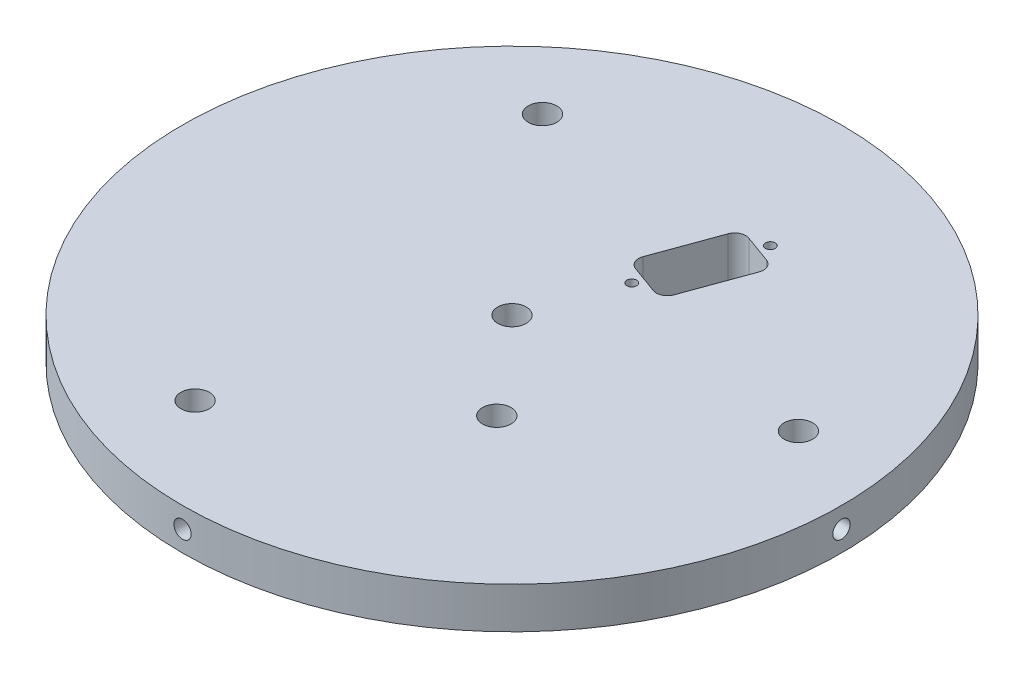
from build123d import *

# Parameters (mm, degrees)
SKETCH1_R                 = 78.359
BOSS_EXTRUDE1_DEPTH       = 25.4
SKETCH6_R                 = 76.1746
BOSS_EXTRUDE5_DEPTH       = 9.525
SKETCH7_R                 = 76.1746
BOSS_EXTRUDE6_DEPTH       = 9.525
SKETCH8_R                 = 73.025
CUT_EXTRUDE5_DEPTH        = 34.925
SKETCH3_R                 = 2
CUT_EXTRUDE2_DEPTH        = 9.525
CUT_EXTRUDE3_START        = 25.4
SKETCH1_7_R               = 78.359
SKETCH1_7_R_2             = 76.1746
CUT_EXTRUDE3_DEPTH        = 9.525
CIRPATTERN2_COUNT         = 3
SKETCH4_R                 = 73.025
BOSS_EXTRUDE4_DEPTH       = 9.525
CIRPATTERN3_COUNT         = 4
SKETCH9_R                 = 3.3
CUT_EXTRUDE6_DEPTH        = 45.4500001
SKETCH10_R                = 82.322787435
CUT_EXTRUDE7_DEPTH        = 35.9250001
TAP_DRILL_FOR_4_40_TAP1_D = 2.2606
CUT_EXTRUDE9_DEPTH        = 10.5250001


with BuildPart() as part:
    # Sketch1 → Boss-Extrude1 (new body)
    with BuildSketch(Plane(origin=(0, 0, 0), x_dir=(1, 0, 0), z_dir=(0, 1, 0))):
        Circle(SKETCH1_R)
    extrude(amount=BOSS_EXTRUDE1_DEPTH)

    # Sketch6 → Boss-Extrude5 (add)
    with BuildSketch(Plane(origin=(0, 25.4, 0), x_dir=(1, 0, 0), z_dir=(0, 1, 0))):
        Circle(SKETCH6_R)
    extrude(amount=BOSS_EXTRUDE5_DEPTH)

    # Sketch7 → Boss-Extrude6 (add)
    with BuildSketch(Plane.XZ):
        Circle(SKETCH7_R)
    extrude(amount=BOSS_EXTRUDE6_DEPTH)

    # Sketch8 → Cut-Extrude5 (cut)
    with BuildSketch(Plane.XZ.offset(9.525)):
        Circle(SKETCH8_R)
    extrude(amount=-CUT_EXTRUDE5_DEPTH, mode=Mode.SUBTRACT)

    # Sketch3 → Cut-Extrude2 (cut)
    with BuildSketch(Plane(origin=(0, 0, -76.1746), x_dir=(-1, 0, 0), z_dir=(0, 0, -1))):
        with Locations((0, 30.1625)):
            Circle(SKETCH3_R)
        with Locations((0, -4.7625)):
            Circle(SKETCH3_R)
    cut_extrude2 = extrude(amount=-CUT_EXTRUDE2_DEPTH, mode=Mode.SUBTRACT)

    # Sketch1_7 → Cut-Extrude3 (cut)
    with BuildSketch(Plane(origin=(0, 0, 0), x_dir=(1, 0, 0), z_dir=(0, 1, 0)).offset(CUT_EXTRUDE3_START)):
        Circle(SKETCH1_7_R)
        Circle(SKETCH1_7_R_2, mode=Mode.SUBTRACT)
    cut_extrude3 = extrude(amount=-CUT_EXTRUDE3_DEPTH, mode=Mode.SUBTRACT)

    # CirPattern2: Cut-Extrude3 ×3 about axis
    cirpattern2_axis = Axis((0, 0, 0), (0, 1, 0))
    for i in range(1, CIRPATTERN2_COUNT):
        add(cut_extrude3.rotate(cirpattern2_axis, i * 360 / CIRPATTERN2_COUNT), mode=Mode.SUBTRACT)

    # Sketch4 → Boss-Extrude4 (add)
    with BuildSketch(Plane(origin=(0, 34.925, 0), x_dir=(1, 0, 0), z_dir=(0, 1, 0))):
        Circle(SKETCH4_R)
    extrude(amount=-BOSS_EXTRUDE4_DEPTH)

    # CirPattern3: Cut-Extrude2 ×4 about axis
    cirpattern3_axis = Axis((0, 0, 0), (0, 1, 0))
    for i in range(1, CIRPATTERN3_COUNT):
        add(cut_extrude2.rotate(cirpattern3_axis, i * 360 / CIRPATTERN3_COUNT), mode=Mode.SUBTRACT)

    # Sketch9 → Cut-Extrude6 (cut, through all)
    with BuildSketch(Plane(origin=(0, 34.925, 0), x_dir=(1, 0, 0), z_dir=(0, 1, 0))):
        Circle(SKETCH9_R)
        with Locations((-19.546451191, -53.703433278)):
            Circle(SKETCH9_R)
        with Locations((-36.735311894, 43.779439924)):
            Circle(SKETCH9_R)
        with Locations((56.281763085, 9.923993354)):
            Circle(SKETCH9_R)
        with Locations((18.367655947, -21.889719962)):
            Circle(SKETCH9_R)
    extrude(amount=-CUT_EXTRUDE6_DEPTH, mode=Mode.SUBTRACT)

    # Sketch10 → Cut-Extrude7 (cut, through all)
    with BuildSketch(Plane(origin=(0, 25.4, 0), x_dir=(1, 0, 0), z_dir=(0, 1, 0))):
        Circle(SKETCH10_R)
    extrude(amount=-CUT_EXTRUDE7_DEPTH, mode=Mode.SUBTRACT)

    # Tap Drill for _4-40 Tap1 (through all)
    with Locations(Plane(origin=(0, 34.925, 0), x_dir=(1, 0, 0), z_dir=(0, 1, 0))):
        with Locations((7.384214894, 20.287963683), (15.934718491, 43.780279238)):
            Hole(TAP_DRILL_FOR_4_40_TAP1_D / 2)

    # Sketch14 → Cut-Extrude9 (cut, through all)
    with BuildSketch(Plane(origin=(0, 34.925, 0), x_dir=(1, 0, 0), z_dir=(0, 1, 0))):
        with BuildLine():
            Line((14.64382936, 22.781402035), (19.893154532, 37.203804415))
            ThreePointArc((19.893154532, 37.203804415), (19.808357055, 39.145985964), (18.37506644, 40.459354836))
            Line((18.37506644, 40.459354836), (11.930654446, 42.804928978))
            ThreePointArc((11.930654446, 42.804928978), (9.988472897, 42.720131501), (8.675104025, 41.286840886))
            Line((8.675104025, 41.286840886), (3.425778853, 26.864438506))
            ThreePointArc((3.425778853, 26.864438506), (3.51057633, 24.922256957), (4.943866945, 23.608888085))
            Line((4.943866945, 23.608888085), (11.388278939, 21.263313942))
            ThreePointArc((11.388278939, 21.263313942), (13.330460488, 21.34811142), (14.64382936, 22.781402035))
        make_face()
    extrude(amount=-CUT_EXTRUDE9_DEPTH, mode=Mode.SUBTRACT)


solid = part.part
